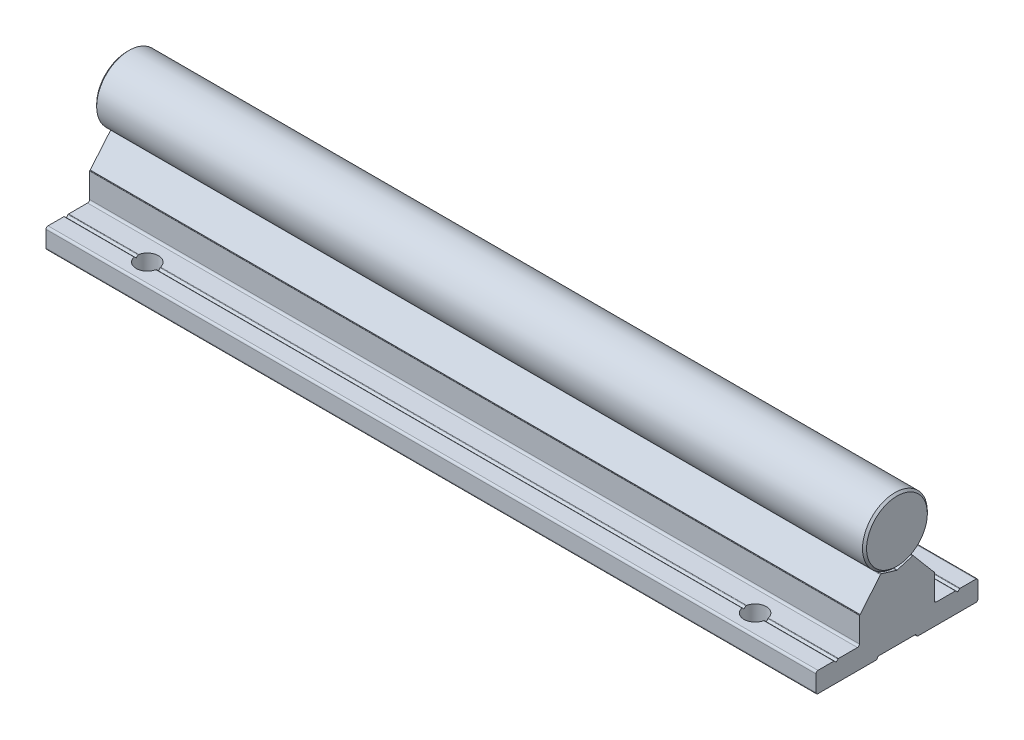
from build123d import *

# Parameters (mm, degrees)
EXTRUDE_3067_DEPTH       = 1500
SKETCH_1_3_R             = 8
EXTRUDE_3196_DEPTH       = 1500
FILLET_4_R               = 0.2
SKETCH_2_R               = 2.75
CUT_EXTRUDE_1_DEPTH      = 6
PATTERN_LINEAR_1_COUNT   = 20
PATTERN_LINEAR_1_PITCH   = 150
PATTERN_LINEAR_2_COUNT   = 20
PATTERN_LINEAR_2_PITCH   = 150
FILLET_1_R               = 0.3
CUT_EXTRUDE_2_DEPTH      = 3
FILLET_2_R               = 0.3
PATTERN_LINEAR_3_COUNT   = 20
PATTERN_LINEAR_3_PITCH   = 150
CHAMFER_1_SIZE           = 0.5
FILLET_3_R               = 0.5
FILLET_5_R               = 0.2
FILLET_6_R               = 0.1
FILLET_7_R               = 0.1
SKETCH_7_W               = 3500
SKETCH_7_H               = 1500
SKETCH_7_W_2             = 190
SKETCH_7_H_2             = 500
CUT_EXTRUDE_3_DEPTH      = 9.0000001
CUT_EXTRUDE_3_DEPTH_BACK = 26.0000001
CHAMFER_2_SIZE           = 0.5


with BuildPart() as part:
    # Sketch 1 → Extrude 3067 (new body, symmetric)
    with BuildSketch(Plane(origin=(0, 0, 0), x_dir=(0, 0, -1), z_dir=(1, 0, 0))):
        Polygon((-20, -25), (-4.75, -25), (-4.75, -24.4), (4.75, -24.4), (4.75, -25), (20, -25), (20, -20), (15.5, -20), (15, -20.5), (14.5, -20), (9.25, -20), (9.25, -13.3), (9.110116754, -13.3), (4, -7.21), (3.8, -7.21), (2.309327639, -7.659439004), (0, -8.355703281), (-2.309327657, -7.659438999), (-3.8, -7.21), (-4, -7.21), (-9.110116754, -13.3), (-9.25, -13.3), (-9.25, -20), (-14.5, -20), (-15, -20.5), (-15.5, -20), (-20, -20), align=None)
    extrude(amount=EXTRUDE_3067_DEPTH, both=True)

    # Fillet 4
    fillet_4_edges = [part.edges().sort_by_distance(p)[0] for p in [
        (0, -20, -15.5),
        (0, -24.4, -4.75),
        (0, -24.4, 4.75),
        (0, -20, 15.5),
        (0, -20, 14.5),
        (0, -8.355703281, 0),
        (0, -20, -14.5),
    ]]
    fillet(fillet_4_edges, radius=FILLET_4_R)

    # Sketch 2 → Cut-Extrude 1 (cut, through all)
    with BuildSketch(Plane(origin=(0, -20, 0), x_dir=(1, 0, 0), z_dir=(0, 1, 0))):
        with Locations((-1425, -15)):
            Circle(SKETCH_2_R)
        with Locations((-1425, 15)):
            Circle(SKETCH_2_R)
        with Locations((-1275, -15)):
            Circle(SKETCH_2_R)
        with Locations((-1275, 15)):
            Circle(SKETCH_2_R)
        with Locations((-1125, -15)):
            Circle(SKETCH_2_R)
        with Locations((-1125, 15)):
            Circle(SKETCH_2_R)
        with Locations((-975, -15)):
            Circle(SKETCH_2_R)
        with Locations((-975, 15)):
            Circle(SKETCH_2_R)
        with Locations((-825, -15)):
            Circle(SKETCH_2_R)
        with Locations((-825, 15)):
            Circle(SKETCH_2_R)
        with Locations((-675, -15)):
            Circle(SKETCH_2_R)
        with Locations((-675, 15)):
            Circle(SKETCH_2_R)
        with Locations((-525, -15)):
            Circle(SKETCH_2_R)
        with Locations((-525, 15)):
            Circle(SKETCH_2_R)
        with Locations((-375, -15)):
            Circle(SKETCH_2_R)
        with Locations((-375, 15)):
            Circle(SKETCH_2_R)
        with Locations((-225, -15)):
            Circle(SKETCH_2_R)
        with Locations((-225, 15)):
            Circle(SKETCH_2_R)
        with Locations((-75, -15)):
            Circle(SKETCH_2_R)
        with Locations((-75, 15)):
            Circle(SKETCH_2_R)
        with Locations((75, -15)):
            Circle(SKETCH_2_R)
        with Locations((75, 15)):
            Circle(SKETCH_2_R)
        with Locations((225, -15)):
            Circle(SKETCH_2_R)
        with Locations((225, 15)):
            Circle(SKETCH_2_R)
        with Locations((375, -15)):
            Circle(SKETCH_2_R)
        with Locations((375, 15)):
            Circle(SKETCH_2_R)
        with Locations((525, -15)):
            Circle(SKETCH_2_R)
        with Locations((525, 15)):
            Circle(SKETCH_2_R)
        with Locations((675, -15)):
            Circle(SKETCH_2_R)
        with Locations((675, 15)):
            Circle(SKETCH_2_R)
        with Locations((825, -15)):
            Circle(SKETCH_2_R)
        with Locations((825, 15)):
            Circle(SKETCH_2_R)
        with Locations((975, -15)):
            Circle(SKETCH_2_R)
        with Locations((975, 15)):
            Circle(SKETCH_2_R)
        with Locations((1125, -15)):
            Circle(SKETCH_2_R)
        with Locations((1125, 15)):
            Circle(SKETCH_2_R)
        with Locations((1275, -15)):
            Circle(SKETCH_2_R)
        with Locations((1275, 15)):
            Circle(SKETCH_2_R)
        with Locations((1425, -15)):
            Circle(SKETCH_2_R)
        with Locations((1425, 15)):
            Circle(SKETCH_2_R)
    extrude(amount=-CUT_EXTRUDE_1_DEPTH, mode=Mode.SUBTRACT)

    # Sketch 3 → Cut-Revolve 1 (revolve, cut)
    with BuildSketch(Plane.XY):
        Polygon((-1425, 0), (-1427.2, -1.270170592), (-1427.2, -7.5), (-1427.75, -7.5), (-1427.75, -19), (-1429.75, -19), (-1429.75, -24.4), (-1425, -24.4), align=None)
    cut_revolve_1 = revolve(axis=Axis((-1425, 56.434869358, 0), (0, -1, 0)), mode=Mode.SUBTRACT)

    # Pattern Linear 1: Cut-Revolve 1 ×20
    with Locations(*[(i * PATTERN_LINEAR_1_PITCH, 0, 0) for i in range(1, PATTERN_LINEAR_1_COUNT)]):
        add(cut_revolve_1, mode=Mode.SUBTRACT)

    # Fillet 3
    fillet_3_edges = [part.edges().sort_by_distance(p)[0] for p in [
        (0, -20, -9.25),
        (0, -20, -20),
        (0, -25, -20),
        (0, -25, -4.75),
        (0, -25, 4.75),
        (0, -20, 9.25),
        (0, -25, 20),
        (0, -20, 20),
    ]]
    fillet(fillet_3_edges, radius=FILLET_3_R)

    # Fillet 5
    fillet_5_edges = [part.edges().sort_by_distance(p)[0] for p in [
        (0, -7.21, 4),
        (0, -7.21, 3.8),
        (0, -7.21, -3.8),
        (0, -7.21, -4),
    ]]
    fillet(fillet_5_edges, radius=FILLET_5_R)

    # Fillet 6
    fillet_6_edges = [part.edges().sort_by_distance(p)[0] for p in [
        (0, -13.3, 9.25),
        (0, -13.3, -9.25),
    ]]
    fillet(fillet_6_edges, radius=FILLET_6_R)

    # Fillet 7
    fillet_7_edges = [part.edges().sort_by_distance(p)[0] for p in [
        (0, -13.3, 9.110116754),
        (0, -13.3, -9.110116754),
    ]]
    fillet(fillet_7_edges, radius=FILLET_7_R)


with BuildPart() as body_2:
    # Sketch 1_3 → Extrude 3196 (new body, symmetric)
    with BuildSketch(Plane(origin=(0, 0, 0), x_dir=(0, 0, -1), z_dir=(1, 0, 0))):
        Circle(SKETCH_1_3_R)
    extrude(amount=EXTRUDE_3196_DEPTH, both=True)

    # Sketch 4 → Cut-Revolve 2 (revolve, cut)
    with BuildSketch(Plane.XY):
        Polygon((-1425, -10), (-1427.2, -10), (-1427.2, -1.270170592), (-1425, 0), align=None)
    cut_revolve_2 = revolve(axis=Axis((-1425, 39.840222878, 0), (0, -1, 0)), mode=Mode.SUBTRACT)

    # Pattern Linear 2: Cut-Revolve 2 ×20
    with Locations(*[(i * PATTERN_LINEAR_2_PITCH, 0, 0) for i in range(1, PATTERN_LINEAR_2_COUNT)]):
        add(cut_revolve_2, mode=Mode.SUBTRACT)

    # Chamfer 1
    chamfer_1_edges = [body_2.edges().sort_by_distance(p)[0] for p in [
        (-1500, 0, 8),
        (1500, 0, 8),
    ]]
    chamfer(chamfer_1_edges, length=CHAMFER_1_SIZE)


with BuildPart() as body_3:
    # Sketch 5 → Revolve 1 (revolve)
    with BuildSketch(Plane.XY):
        Polygon((-1425, -24), (-1429.5, -24), (-1429.5, -19), (-1427.5, -19), (-1427.5, -2.461880215), (-1426.7, -2), (-1425, -2), align=None)
    revolve(axis=Axis((-1425, 35.529626596, 0), (0, -1, 0)))

    # Fillet 1
    fillet_1_edges = [body_3.edges().sort_by_distance(p)[0] for p in [
        (-1420.5, -19, 0),
    ]]
    fillet(fillet_1_edges, radius=FILLET_1_R)

    # Sketch 6 → Cut-Extrude 2 (cut)
    with BuildSketch(Plane.XZ.offset(24)):
        Polygon((-1423.25, -1.010362971), (-1423.25, 1.010362971), (-1425, 2.020725942), (-1426.75, 1.010362971), (-1426.75, -1.010362971), (-1425, -2.020725942), align=None)
    extrude(amount=-CUT_EXTRUDE_2_DEPTH, mode=Mode.SUBTRACT)

    # Fillet 2
    fillet_2_edges = [body_3.edges().sort_by_distance(p)[0] for p in [
        (-1424.125, -24, -1.515544457),
        (-1423.25, -24, 0),
        (-1424.125, -24, 1.515544457),
        (-1425.875, -24, 1.515544457),
        (-1426.75, -24, 0),
        (-1425.875, -24, -1.515544457),
        (-1420.5, -24, 0),
    ]]
    fillet(fillet_2_edges, radius=FILLET_2_R)


with BuildPart() as pattern_linear_3_1:
    # Pattern Linear 3: pattern copy
    add(body_3.part.moved(Location(Vector(1, 0, 0) * (1 * PATTERN_LINEAR_3_PITCH))))


with BuildPart() as pattern_linear_3_2:
    # Pattern Linear 3: pattern copy
    add(body_3.part.moved(Location(Vector(1, 0, 0) * (2 * PATTERN_LINEAR_3_PITCH))))


with BuildPart() as pattern_linear_3_3:
    # Pattern Linear 3: pattern copy
    add(body_3.part.moved(Location(Vector(1, 0, 0) * (3 * PATTERN_LINEAR_3_PITCH))))


with BuildPart() as pattern_linear_3_4:
    # Pattern Linear 3: pattern copy
    add(body_3.part.moved(Location(Vector(1, 0, 0) * (4 * PATTERN_LINEAR_3_PITCH))))


with BuildPart() as pattern_linear_3_5:
    # Pattern Linear 3: pattern copy
    add(body_3.part.moved(Location(Vector(1, 0, 0) * (5 * PATTERN_LINEAR_3_PITCH))))


with BuildPart() as pattern_linear_3_6:
    # Pattern Linear 3: pattern copy
    add(body_3.part.moved(Location(Vector(1, 0, 0) * (6 * PATTERN_LINEAR_3_PITCH))))


with BuildPart() as pattern_linear_3_7:
    # Pattern Linear 3: pattern copy
    add(body_3.part.moved(Location(Vector(1, 0, 0) * (7 * PATTERN_LINEAR_3_PITCH))))


with BuildPart() as pattern_linear_3_8:
    # Pattern Linear 3: pattern copy
    add(body_3.part.moved(Location(Vector(1, 0, 0) * (8 * PATTERN_LINEAR_3_PITCH))))


with BuildPart() as pattern_linear_3_9:
    # Pattern Linear 3: pattern copy
    add(body_3.part.moved(Location(Vector(1, 0, 0) * (9 * PATTERN_LINEAR_3_PITCH))))


with BuildPart() as pattern_linear_3_10:
    # Pattern Linear 3: pattern copy
    add(body_3.part.moved(Location(Vector(1, 0, 0) * (10 * PATTERN_LINEAR_3_PITCH))))


with BuildPart() as pattern_linear_3_11:
    # Pattern Linear 3: pattern copy
    add(body_3.part.moved(Location(Vector(1, 0, 0) * (11 * PATTERN_LINEAR_3_PITCH))))


with BuildPart() as pattern_linear_3_12:
    # Pattern Linear 3: pattern copy
    add(body_3.part.moved(Location(Vector(1, 0, 0) * (12 * PATTERN_LINEAR_3_PITCH))))


with BuildPart() as pattern_linear_3_13:
    # Pattern Linear 3: pattern copy
    add(body_3.part.moved(Location(Vector(1, 0, 0) * (13 * PATTERN_LINEAR_3_PITCH))))


with BuildPart() as pattern_linear_3_14:
    # Pattern Linear 3: pattern copy
    add(body_3.part.moved(Location(Vector(1, 0, 0) * (14 * PATTERN_LINEAR_3_PITCH))))


with BuildPart() as pattern_linear_3_15:
    # Pattern Linear 3: pattern copy
    add(body_3.part.moved(Location(Vector(1, 0, 0) * (15 * PATTERN_LINEAR_3_PITCH))))


with BuildPart() as pattern_linear_3_16:
    # Pattern Linear 3: pattern copy
    add(body_3.part.moved(Location(Vector(1, 0, 0) * (16 * PATTERN_LINEAR_3_PITCH))))


with BuildPart() as pattern_linear_3_17:
    # Pattern Linear 3: pattern copy
    add(body_3.part.moved(Location(Vector(1, 0, 0) * (17 * PATTERN_LINEAR_3_PITCH))))


with BuildPart() as pattern_linear_3_18:
    # Pattern Linear 3: pattern copy
    add(body_3.part.moved(Location(Vector(1, 0, 0) * (18 * PATTERN_LINEAR_3_PITCH))))


with BuildPart() as pattern_linear_3_19:
    # Pattern Linear 3: pattern copy
    add(body_3.part.moved(Location(Vector(1, 0, 0) * (19 * PATTERN_LINEAR_3_PITCH))))


with BuildPart() as cut_extrude_3_tool:
    # Sketch 7 → Cut-Extrude 3 (new body, two sides)
    with BuildSketch(Plane(origin=(0, 0, 0), x_dir=(1, 0, 0), z_dir=(0, 1, 0))) as cut_extrude_3_sk:
        Rectangle(SKETCH_7_W, SKETCH_7_H)
        with Locations((1350, 0)):
            Rectangle(SKETCH_7_W_2, SKETCH_7_H_2, mode=Mode.SUBTRACT)
    extrude(amount=CUT_EXTRUDE_3_DEPTH)
    extrude(cut_extrude_3_sk.sketch, amount=-CUT_EXTRUDE_3_DEPTH_BACK)


with BuildPart() as part_1:
    add(part.part)

    # Cut-Extrude 3: cut by cut_extrude_3_tool
    add(cut_extrude_3_tool.part, mode=Mode.SUBTRACT)


with BuildPart() as body_2_1:
    add(body_2.part)

    # Cut-Extrude 3: cut by cut_extrude_3_tool
    add(cut_extrude_3_tool.part, mode=Mode.SUBTRACT)

    # Chamfer 2
    chamfer_2_edges = [body_2_1.edges().sort_by_distance(p)[0] for p in [
        (1255, 0, 8),
        (1445, 0, 8),
    ]]
    chamfer(chamfer_2_edges, length=CHAMFER_2_SIZE)


with BuildPart() as body_3_1:
    add(body_3.part)

    # Cut-Extrude 3: cut by cut_extrude_3_tool
    add(cut_extrude_3_tool.part, mode=Mode.SUBTRACT)


with BuildPart() as pattern_linear_3_1_1:
    add(pattern_linear_3_1.part)

    # Cut-Extrude 3: cut by cut_extrude_3_tool
    add(cut_extrude_3_tool.part, mode=Mode.SUBTRACT)


with BuildPart() as pattern_linear_3_2_1:
    add(pattern_linear_3_2.part)

    # Cut-Extrude 3: cut by cut_extrude_3_tool
    add(cut_extrude_3_tool.part, mode=Mode.SUBTRACT)


with BuildPart() as pattern_linear_3_3_1:
    add(pattern_linear_3_3.part)

    # Cut-Extrude 3: cut by cut_extrude_3_tool
    add(cut_extrude_3_tool.part, mode=Mode.SUBTRACT)


with BuildPart() as pattern_linear_3_4_1:
    add(pattern_linear_3_4.part)

    # Cut-Extrude 3: cut by cut_extrude_3_tool
    add(cut_extrude_3_tool.part, mode=Mode.SUBTRACT)


with BuildPart() as pattern_linear_3_5_1:
    add(pattern_linear_3_5.part)

    # Cut-Extrude 3: cut by cut_extrude_3_tool
    add(cut_extrude_3_tool.part, mode=Mode.SUBTRACT)


with BuildPart() as pattern_linear_3_6_1:
    add(pattern_linear_3_6.part)

    # Cut-Extrude 3: cut by cut_extrude_3_tool
    add(cut_extrude_3_tool.part, mode=Mode.SUBTRACT)


with BuildPart() as pattern_linear_3_7_1:
    add(pattern_linear_3_7.part)

    # Cut-Extrude 3: cut by cut_extrude_3_tool
    add(cut_extrude_3_tool.part, mode=Mode.SUBTRACT)


with BuildPart() as pattern_linear_3_8_1:
    add(pattern_linear_3_8.part)

    # Cut-Extrude 3: cut by cut_extrude_3_tool
    add(cut_extrude_3_tool.part, mode=Mode.SUBTRACT)


with BuildPart() as pattern_linear_3_9_1:
    add(pattern_linear_3_9.part)

    # Cut-Extrude 3: cut by cut_extrude_3_tool
    add(cut_extrude_3_tool.part, mode=Mode.SUBTRACT)


with BuildPart() as pattern_linear_3_10_1:
    add(pattern_linear_3_10.part)

    # Cut-Extrude 3: cut by cut_extrude_3_tool
    add(cut_extrude_3_tool.part, mode=Mode.SUBTRACT)


with BuildPart() as pattern_linear_3_11_1:
    add(pattern_linear_3_11.part)

    # Cut-Extrude 3: cut by cut_extrude_3_tool
    add(cut_extrude_3_tool.part, mode=Mode.SUBTRACT)


with BuildPart() as pattern_linear_3_12_1:
    add(pattern_linear_3_12.part)

    # Cut-Extrude 3: cut by cut_extrude_3_tool
    add(cut_extrude_3_tool.part, mode=Mode.SUBTRACT)


with BuildPart() as pattern_linear_3_13_1:
    add(pattern_linear_3_13.part)

    # Cut-Extrude 3: cut by cut_extrude_3_tool
    add(cut_extrude_3_tool.part, mode=Mode.SUBTRACT)


with BuildPart() as pattern_linear_3_14_1:
    add(pattern_linear_3_14.part)

    # Cut-Extrude 3: cut by cut_extrude_3_tool
    add(cut_extrude_3_tool.part, mode=Mode.SUBTRACT)


with BuildPart() as pattern_linear_3_15_1:
    add(pattern_linear_3_15.part)

    # Cut-Extrude 3: cut by cut_extrude_3_tool
    add(cut_extrude_3_tool.part, mode=Mode.SUBTRACT)


with BuildPart() as pattern_linear_3_16_1:
    add(pattern_linear_3_16.part)

    # Cut-Extrude 3: cut by cut_extrude_3_tool
    add(cut_extrude_3_tool.part, mode=Mode.SUBTRACT)


with BuildPart() as pattern_linear_3_17_1:
    add(pattern_linear_3_17.part)

    # Cut-Extrude 3: cut by cut_extrude_3_tool
    add(cut_extrude_3_tool.part, mode=Mode.SUBTRACT)


solid = Compound([pattern_linear_3_18.part, pattern_linear_3_19.part, part_1.part, body_2_1.part])
